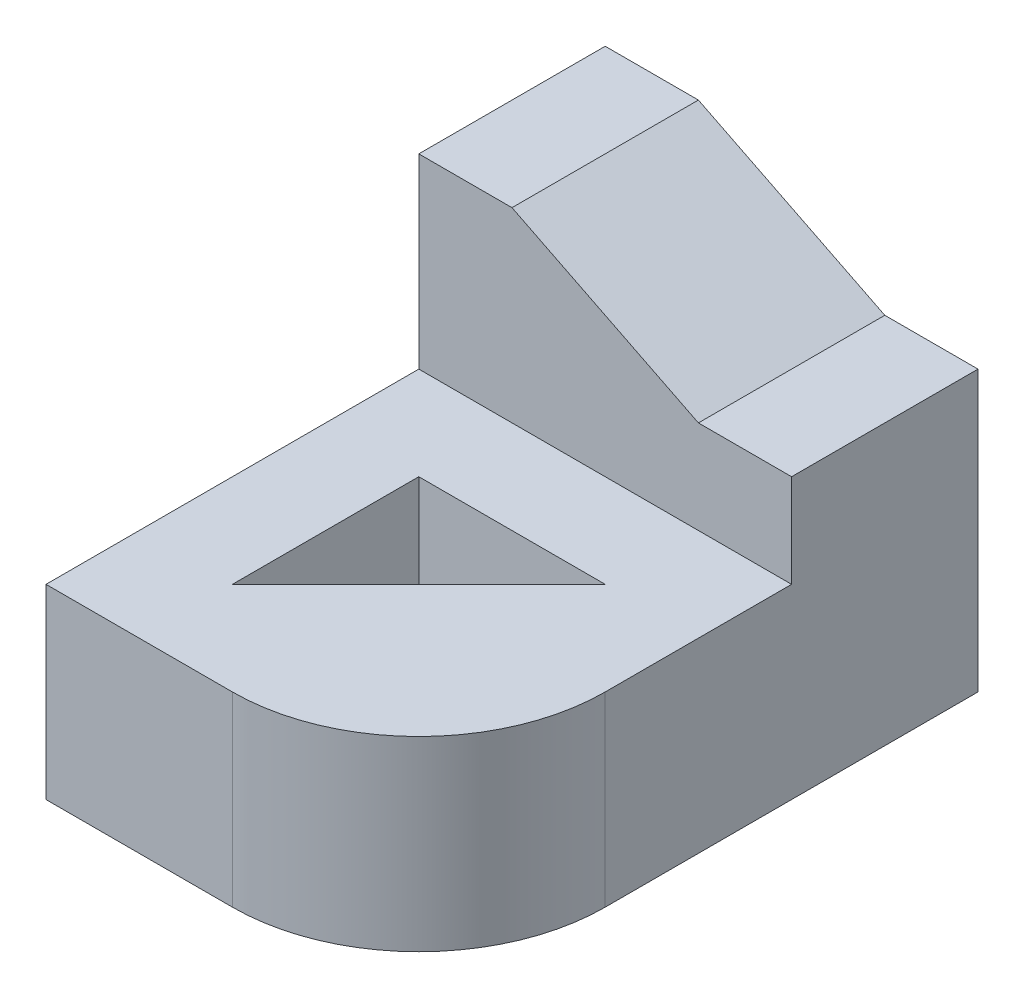
from build123d import *

# Parameters (mm, degrees)
EXTRUDE_1_DEPTH     = 10
SKETCH_1_3_W        = 20
SKETCH_1_3_H        = 10
EXTRUDE_2_DEPTH     = 20
CUT_EXTRUDE_1_DEPTH = 20
FILLET_1_R          = 10
SCALE_1_SCALE       = 0.2


with BuildPart() as part:
    # 草圖1 → 填料-伸長1 (new body)
    with BuildSketch(Plane(origin=(0, 0, 0), x_dir=(1, 0, 0), z_dir=(0, 1, 0))):
        Polygon((-5, 10), (-10, 10), (-10, -10), (10, -10), (10, 10), (5, 10), align=None)
        Polygon((-5, 5), (5, 5), (-5, -5), align=None, mode=Mode.SUBTRACT)
    extrude(amount=EXTRUDE_1_DEPTH)

    # 草圖1<3> → 填料-伸長2 (add)
    with BuildSketch(Plane(origin=(0, 0, 0), x_dir=(1, 0, 0), z_dir=(0, 1, 0))):
        with Locations((0, 15)):
            Rectangle(SKETCH_1_3_W, SKETCH_1_3_H)
    extrude(amount=EXTRUDE_2_DEPTH)

    # 草圖2 → 除料-伸長1 (cut)
    with BuildSketch(Plane.XY.offset(-10)):
        Polygon((-5, 20), (5, 15), (10, 15), (10, 20), align=None)
    extrude(amount=-CUT_EXTRUDE_1_DEPTH, mode=Mode.SUBTRACT)

    # 圓角1
    fillet_1_edges = [part.edges().sort_by_distance(p)[0] for p in [
        (10, 5, 10),
    ]]
    fillet(fillet_1_edges, radius=FILLET_1_R)


with BuildPart() as part_1:
    # 縮放比例1: scaled about (-0.460547771, 6.995707008, -7.860015293)
    add(part.part.scale(SCALE_1_SCALE).moved(Location((-0.368438217, 5.596565606, -6.288012234))))


solid = part_1.part
